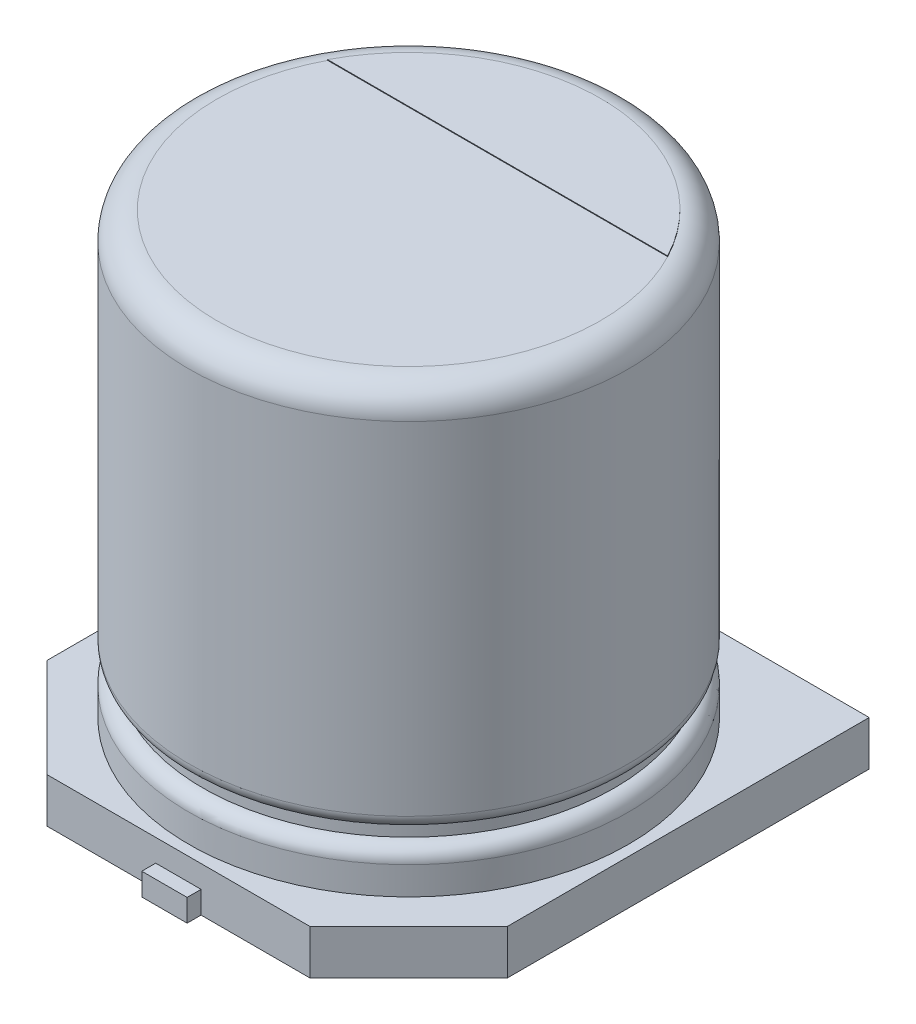
from build123d import *

# Parameters (mm, degrees)
BOSS_EXTRUDE1_DEPTH = 0.01
BOSS_EXTRUDE2_DEPTH = 0.64
CUT_EXTRUDE1_START  = 0.64
CUT_EXTRUDE1_DEPTH  = 0.32
SKETCH4_W           = 0.65
SKETCH4_H           = 2.6
BOSS_EXTRUDE3_DEPTH = 0.32


with BuildPart() as part:
    # Sketch1 → Revolve1 (revolve)
    with BuildSketch(Plane.XY):
        with BuildLine():
            Line((0, 6.3), (-2.75, 6.3))
            ThreePointArc((-2.75, 6.3), (-3.032842712, 6.182842712), (-3.15, 5.9))
            Line((-3.15, 5.9), (-3.15, 1))
            ThreePointArc((-3.15, 1), (-3.091421356, 0.858578644), (-2.95, 0.8))
            Line((-2.95, 0.8), (-2.95, 0.6))
            ThreePointArc((-2.95, 0.6), (-3.091421356, 0.541421356), (-3.15, 0.4))
            Line((-3.15, 0.4), (-3.15, 0))
            Line((-3.15, 0), (0, 0))
            Line((0, 0), (0, 6.3))
        make_face()
    revolve(axis=Axis((0, 8.082229881, 0), (0, -1, 0)))

    # Sketch2 → Boss-Extrude1 (add)
    with BuildSketch(Plane(origin=(0, 6.3, 0), x_dir=(1, 0, 0), z_dir=(0, 1, 0))):
        with BuildLine():
            Line((-2.436570336, 1.275), (2.436570336, 1.275))
            ThreePointArc((2.436570336, 1.275), (0, 2.75), (-2.436570336, 1.275))
        make_face()
    extrude(amount=BOSS_EXTRUDE1_DEPTH)

    # Sketch3 → Boss-Extrude2 (add)
    with BuildSketch(Plane(origin=(0, 0, 0), x_dir=(-1, 0, 0), z_dir=(0, -1, 0))):
        Polygon((1.885786438, -3.3), (3.3, -1.885786438), (3.3, 3.3), (-3.3, 3.3), (-3.3, -1.885786438), (-1.885786438, -3.3), align=None)
    extrude(amount=BOSS_EXTRUDE2_DEPTH)

    # Sketch3_3 → Cut-Extrude1 (cut)
    with BuildSketch(Plane(origin=(0, 0, 0), x_dir=(-1, 0, 0), z_dir=(0, -1, 0)).offset(CUT_EXTRUDE1_START)):
        with BuildLine():
            Line((0.325, 0.9), (0.325, 3.13318927))
            ThreePointArc((0.325, 3.13318927), (0, 3.15), (-0.325, 3.13318927))
            Line((-0.325, 3.13318927), (-0.325, 0.9))
            Line((-0.325, 0.9), (0.325, 0.9))
        make_face()
        with BuildLine():
            ThreePointArc((-0.325, -3.13318927), (0, -3.15), (0.325, -3.13318927))
            Line((0.325, -3.13318927), (0.325, -0.9))
            Line((0.325, -0.9), (-0.325, -0.9))
            Line((-0.325, -0.9), (-0.325, -3.13318927))
        make_face()
        with BuildLine():
            Line((0.325, 3.13318927), (0.325, 3.3))
            Line((0.325, 3.3), (-0.325, 3.3))
            Line((-0.325, 3.3), (-0.325, 3.13318927))
            ThreePointArc((-0.325, 3.13318927), (0, 3.15), (0.325, 3.13318927))
        make_face()
        with BuildLine():
            Line((-0.325, -3.3), (0.325, -3.3))
            Line((0.325, -3.3), (0.325, -3.13318927))
            ThreePointArc((0.325, -3.13318927), (0, -3.15), (-0.325, -3.13318927))
            Line((-0.325, -3.13318927), (-0.325, -3.3))
        make_face()
    extrude(amount=-CUT_EXTRUDE1_DEPTH, mode=Mode.SUBTRACT)

    # Sketch4 → Boss-Extrude3 (add)
    with BuildSketch(Plane.XZ.offset(0.32)):
        with Locations((0, -2.2)):
            Rectangle(SKETCH4_W, SKETCH4_H)
        with Locations((0, 2.2)):
            Rectangle(SKETCH4_W, SKETCH4_H)
    extrude(amount=BOSS_EXTRUDE3_DEPTH)


solid = part.part
